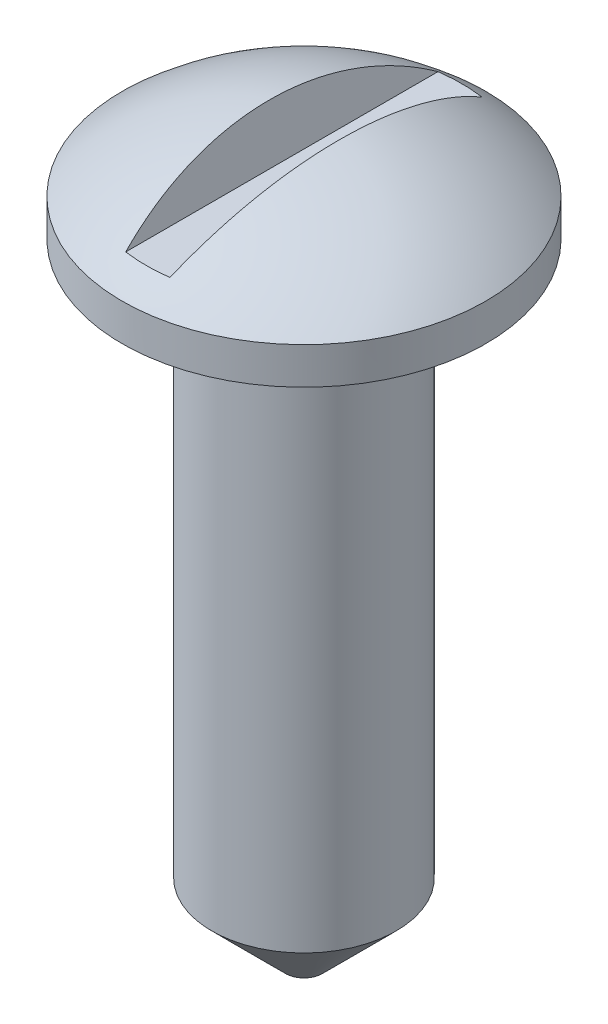
from build123d import *

# Parameters (mm, degrees)
CHAMFER4_SIZE           = 5.08
CUT_EXTRUDE2_DEPTH      = 13.517807
CUT_EXTRUDE2_DEPTH_BACK = 13.517807


with BuildPart() as part:
    # Sketch1 one side → Revolve13 (revolve)
    with BuildSketch(Plane.XY):
        Polygon((-6.35, 43.18), (-6.35, 0), (0, 0), (0, 45.72), (-12.517807, 45.72), (-12.517807, 43.18), align=None)
        with BuildLine():
            ThreePointArc((0, 50.41009), (-6.683794, 49.199075), (-12.517807, 45.72))
            Line((-12.517807, 45.72), (0, 45.72))
            Line((0, 45.72), (0, 50.41009))
        make_face()
    revolve(axis=Axis((0, -10.13615, 0), (0, 1, 0)))

    # Chamfer4
    chamfer4_edges = [part.edges().sort_by_distance(p)[0] for p in [
        (6.35, 0, 0),
    ]]
    chamfer(chamfer4_edges, length=CHAMFER4_SIZE)

    # Sketch4 → Cut-Extrude2 (cut, two sides)
    with BuildSketch(Plane.XY) as cut_extrude2_sk:
        Polygon((-32.117638, 161.194555), (-2.39261, 50.259241), (-1.522582, 47.012254), (1.522582, 47.012254), (2.39261, 50.259241), (32.117638, 161.194555), (32.117638, 390.891931), (-32.117638, 390.891931), align=None)
    extrude(amount=CUT_EXTRUDE2_DEPTH, mode=Mode.SUBTRACT)
    extrude(cut_extrude2_sk.sketch, amount=-CUT_EXTRUDE2_DEPTH_BACK, mode=Mode.SUBTRACT)


solid = part.part
